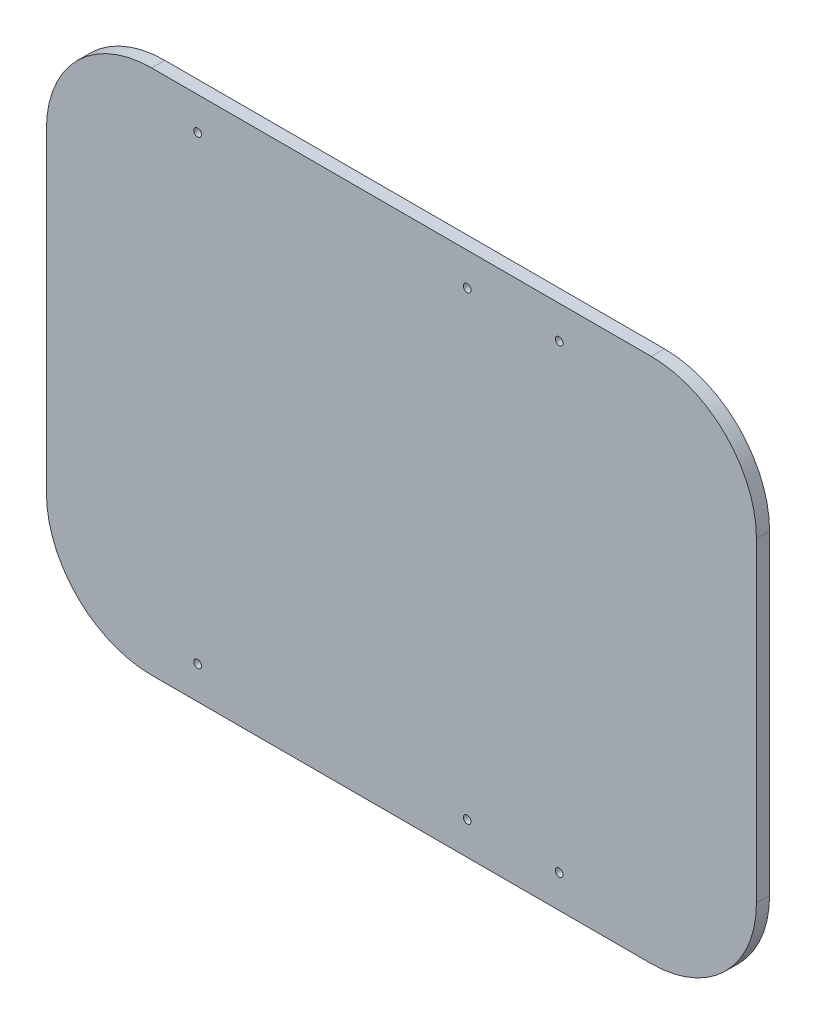
from build123d import *

# Parameters (mm, degrees)
SKETCH2_R           = 1.475
BOSS_EXTRUDE1_DEPTH = 5


with BuildPart() as part:
    # Sketch2 → Boss-Extrude1 (new body)
    with BuildSketch(Plane.XY):
        with BuildLine():
            Line((-95, 100), (95, 100))
            ThreePointArc((95, 100), (123.284271247, 88.284271247), (135, 60))
            Line((135, 60), (135, -60))
            ThreePointArc((135, -60), (123.284271247, -88.284271247), (95, -100))
            Line((95, -100), (-95, -100))
            ThreePointArc((-95, -100), (-123.284271247, -88.284271247), (-135, -60))
            Line((-135, -60), (-135, 60))
            ThreePointArc((-135, 60), (-123.284271247, 88.284271247), (-95, 100))
        make_face()
        with Locations((-77.5, 87.5)):
            Circle(SKETCH2_R, mode=Mode.SUBTRACT)
        with Locations((25, 87.5)):
            Circle(SKETCH2_R, mode=Mode.SUBTRACT)
        with Locations((60, 87.5)):
            Circle(SKETCH2_R, mode=Mode.SUBTRACT)
        with Locations((60, -87.5)):
            Circle(SKETCH2_R, mode=Mode.SUBTRACT)
        with Locations((25, -87.5)):
            Circle(SKETCH2_R, mode=Mode.SUBTRACT)
        with Locations((-77.5, -87.5)):
            Circle(SKETCH2_R, mode=Mode.SUBTRACT)
    extrude(amount=BOSS_EXTRUDE1_DEPTH)


solid = part.part
